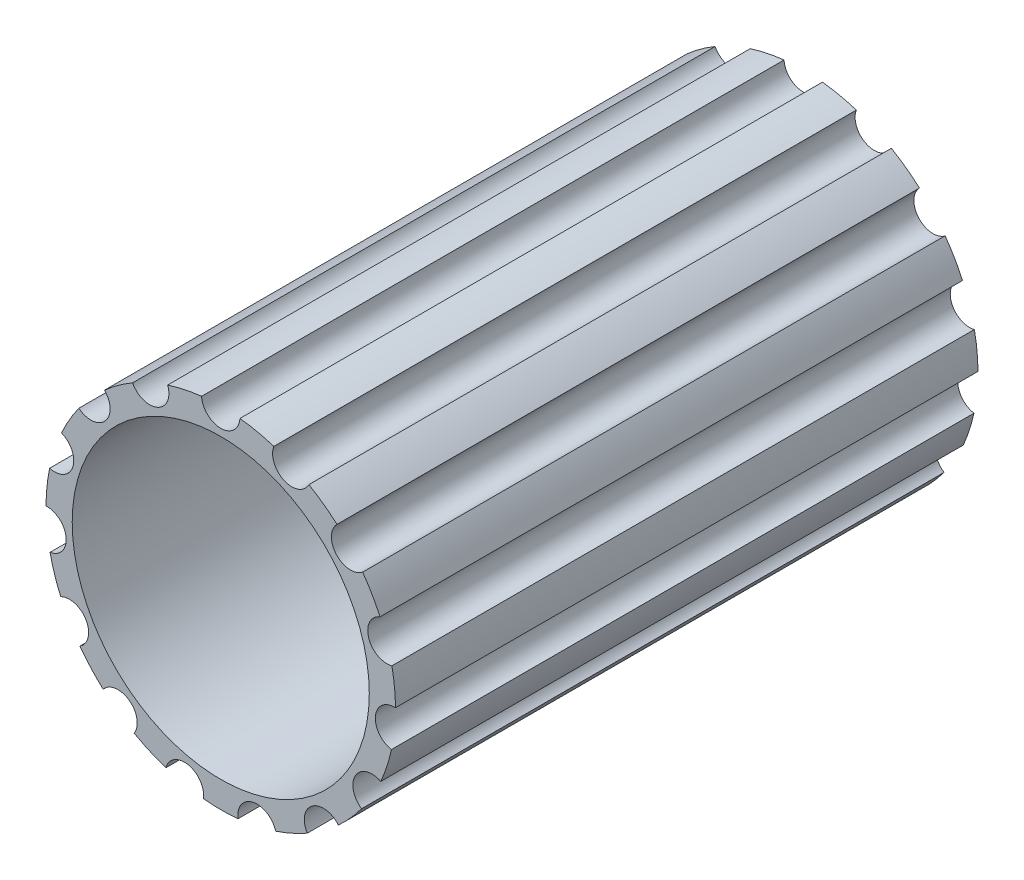
from build123d import *

# Parameters (mm, degrees)
BOSS_EXTRUDE1_DEPTH = 10
SKETCH2_R           = 2.55
CUT_EXTRUDE1_DEPTH  = 10


with BuildPart() as part:
    # Sketch1 → Boss-Extrude1 (new body)
    with BuildSketch(Plane.XY):
        with BuildLine():
            ThreePointArc((0.329389796, 2.981862231), (0.623735072, 2.934442802), (0.911920082, 2.858041596))
            ThreePointArc((0.911920082, 2.858041596), (1.086032069, 2.439267964), (1.513745185, 2.590091796))
            ThreePointArc((1.513745185, 2.590091796), (1.763355757, 2.427050983), (1.995550693, 2.240039605))
            ThreePointArc((1.995550693, 2.240039605), (1.984279326, 1.786653131), (2.436360281, 1.75047096))
            ThreePointArc((2.436360281, 1.75047096), (2.598076211, 1.5), (2.734132461, 1.234714416))
            ThreePointArc((2.734132461, 1.234714416), (2.539426662, 0.82510974), (2.93770655, 0.608177793))
            ThreePointArc((2.93770655, 0.608177793), (2.983565686, 0.31358539), (2.999957886, 0.015895887))
            ThreePointArc((2.999957886, 0.015895887), (2.655484058, -0.279102621), (2.931096668, -0.639274841))
            ThreePointArc((2.931096668, -0.639274841), (2.853169549, -0.927050983), (2.74706334, -1.205671185))
            ThreePointArc((2.74706334, -1.205671185), (2.312384136, -1.335055603), (2.417673544, -1.776191046))
            ThreePointArc((2.417673544, -1.776191046), (2.229434476, -2.007391819), (2.019176586, -2.218766755))
            ThreePointArc((2.019176586, -2.218766755), (1.569451989, -2.160165343), (1.486212701, -2.605987684))
            ThreePointArc((1.486212701, -2.605987684), (1.220209929, -2.740636373), (0.942155856, -2.848217397))
            ThreePointArc((0.942155856, -2.848217397), (0.555147336, -2.61176287), (0.29777218, -2.985185376))
            ThreePointArc((0.29777218, -2.985185376), (0, -3), (-0.29777218, -2.985185376))
            ThreePointArc((-0.29777218, -2.985185376), (-0.555147336, -2.61176287), (-0.942155856, -2.848217397))
            ThreePointArc((-0.942155856, -2.848217397), (-1.220209929, -2.740636373), (-1.486212701, -2.605987684))
            ThreePointArc((-1.486212701, -2.605987684), (-1.569451989, -2.160165343), (-2.019176586, -2.218766755))
            ThreePointArc((-2.019176586, -2.218766755), (-2.229434476, -2.007391819), (-2.417673544, -1.776191046))
            ThreePointArc((-2.417673544, -1.776191046), (-2.312384136, -1.335055603), (-2.74706334, -1.205671185))
            ThreePointArc((-2.74706334, -1.205671185), (-2.853169549, -0.927050983), (-2.931096668, -0.639274841))
            ThreePointArc((-2.931096668, -0.639274841), (-2.655484058, -0.279102621), (-2.999957886, 0.015895887))
            ThreePointArc((-2.999957886, 0.015895887), (-2.983565686, 0.31358539), (-2.93770655, 0.608177793))
            ThreePointArc((-2.93770655, 0.608177793), (-2.539426662, 0.82510974), (-2.734132461, 1.234714416))
            ThreePointArc((-2.734132461, 1.234714416), (-2.598076211, 1.5), (-2.436360281, 1.75047096))
            ThreePointArc((-2.436360281, 1.75047096), (-1.984279326, 1.786653131), (-1.995550693, 2.240039605))
            ThreePointArc((-1.995550693, 2.240039605), (-1.763355757, 2.427050983), (-1.513745185, 2.590091796))
            ThreePointArc((-1.513745185, 2.590091796), (-1.086032069, 2.439267964), (-0.911920082, 2.858041596))
            ThreePointArc((-0.911920082, 2.858041596), (-0.623735072, 2.934442802), (-0.329389796, 2.981862231))
            ThreePointArc((-0.329389796, 2.981862231), (0, 2.670111206), (0.329389796, 2.981862231))
        make_face()
    extrude(amount=BOSS_EXTRUDE1_DEPTH)

    # Sketch2 → Cut-Extrude1 (cut)
    with BuildSketch(Plane.XY.offset(10)):
        Circle(SKETCH2_R)
    extrude(amount=-CUT_EXTRUDE1_DEPTH, mode=Mode.SUBTRACT)


solid = part.part
